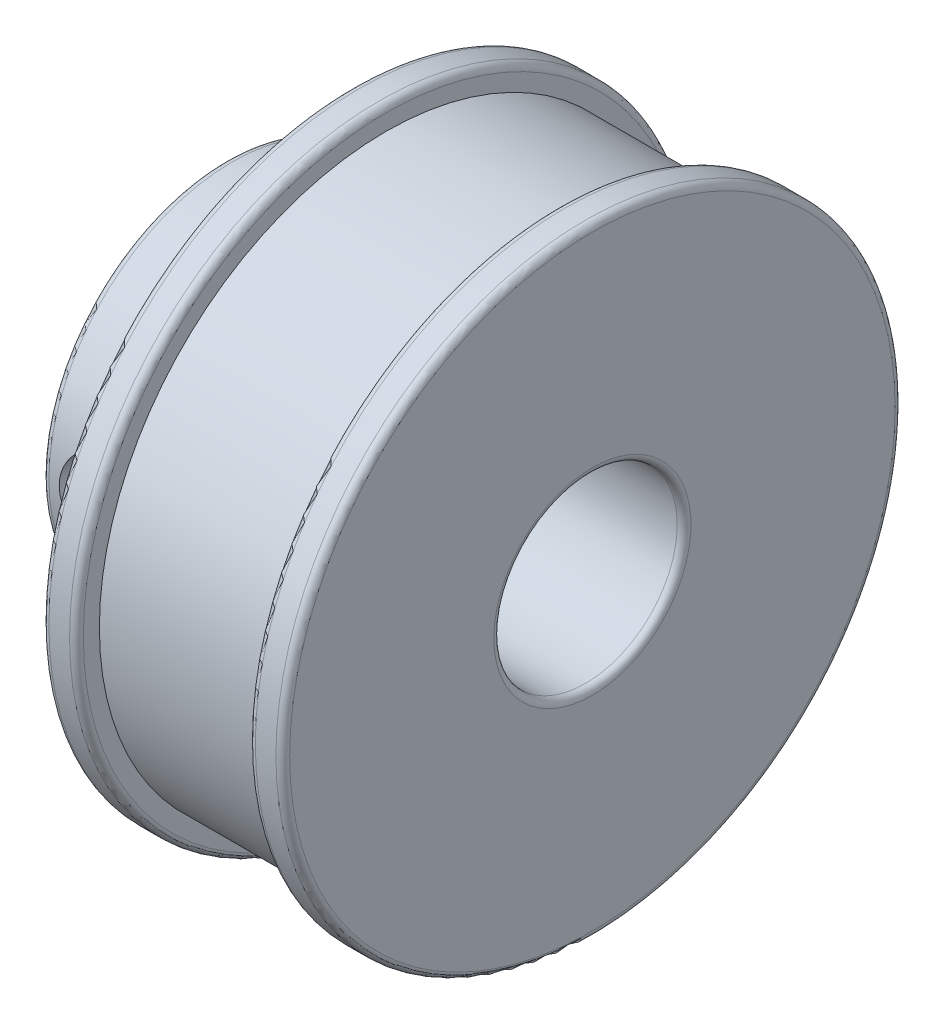
from build123d import *

# Parameters (mm, degrees)
FILLET1_R               = 0.3
SKETCH2_R               = 2
CUT_EXTRUDE1_DEPTH      = 14.5000001
CUT_EXTRUDE1_DEPTH_BACK = 14.5000001


with BuildPart() as part:
    # Sketch1 → Revolve1 (revolve)
    with BuildSketch(Plane(origin=(0, 0, 0), x_dir=(1, 0, 0), z_dir=(0, 1, 0))):
        Polygon((0, 4), (0, 8), (5.5, 8), (5.5, 13.5), (7, 13.5), (7, 12.5), (14.5, 12.5), (14.5, 13.5), (16, 13.5), (16, 4), align=None)
    revolve(axis=Axis((0, 0, 0), (1, 0, 0)))

    # Fillet1
    fillet1_edges = [part.edges().sort_by_distance(p)[0] for p in [
        (7, 0, 13.5),
        (5.5, 0, 13.5),
        (0, 0, 8),
        (0, 0, 4),
        (16, 0, 4),
        (16, 0, 13.5),
        (14.5, 0, 13.5),
    ]]
    fillet(fillet1_edges, radius=FILLET1_R)

    # Sketch2 → Cut-Extrude1 (cut, two sides)
    with BuildSketch(Plane.XY) as cut_extrude1_sk:
        with Locations((2.75, 0)):
            Circle(SKETCH2_R)
    extrude(amount=CUT_EXTRUDE1_DEPTH, mode=Mode.SUBTRACT)
    extrude(cut_extrude1_sk.sketch, amount=-CUT_EXTRUDE1_DEPTH_BACK, mode=Mode.SUBTRACT)


solid = part.part
